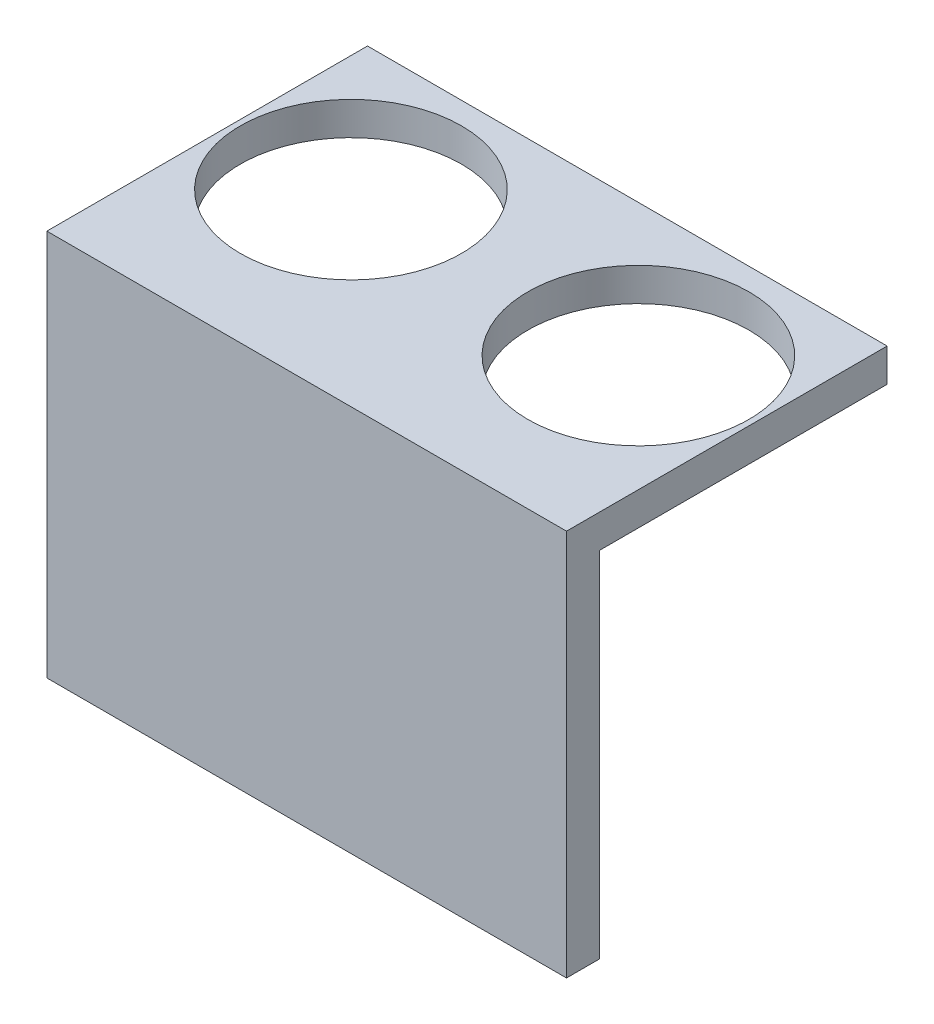
from build123d import *

# Parameters (mm, degrees)
SKETCH1_W           = 47
SKETCH1_H           = 24
SKETCH1_R           = 10
BOSS_EXTRUDE1_DEPTH = 3
SKETCH2_W           = 47
SKETCH2_H           = 2
BOSS_EXTRUDE2_DEPTH = 3
SKETCH3_W           = 47
SKETCH3_H           = 3
BOSS_EXTRUDE6_DEPTH = 35


with BuildPart() as part:
    # Sketch1 → Boss-Extrude1 (new body)
    with BuildSketch(Plane(origin=(0, 0, 0), x_dir=(1, 0, 0), z_dir=(0, 1, 0))):
        Rectangle(SKETCH1_W, SKETCH1_H)
        with Locations((-13, 0)):
            Circle(SKETCH1_R, mode=Mode.SUBTRACT)
        with Locations((13, 0)):
            Circle(SKETCH1_R, mode=Mode.SUBTRACT)
    extrude(amount=BOSS_EXTRUDE1_DEPTH)

    # Sketch2 → Boss-Extrude2 (add)
    with BuildSketch(Plane(origin=(0, 3, 0), x_dir=(1, 0, 0), z_dir=(0, 1, 0))):
        with Locations((0, -13)):
            Rectangle(SKETCH2_W, SKETCH2_H)
    extrude(amount=-BOSS_EXTRUDE2_DEPTH)

    # Sketch3 → Boss-Extrude6 (add)
    with BuildSketch(Plane(origin=(0, 3, 0), x_dir=(1, 0, 0), z_dir=(0, 1, 0))):
        with Locations((0, -15.5)):
            Rectangle(SKETCH3_W, SKETCH3_H)
    extrude(amount=-BOSS_EXTRUDE6_DEPTH)


solid = part.part
